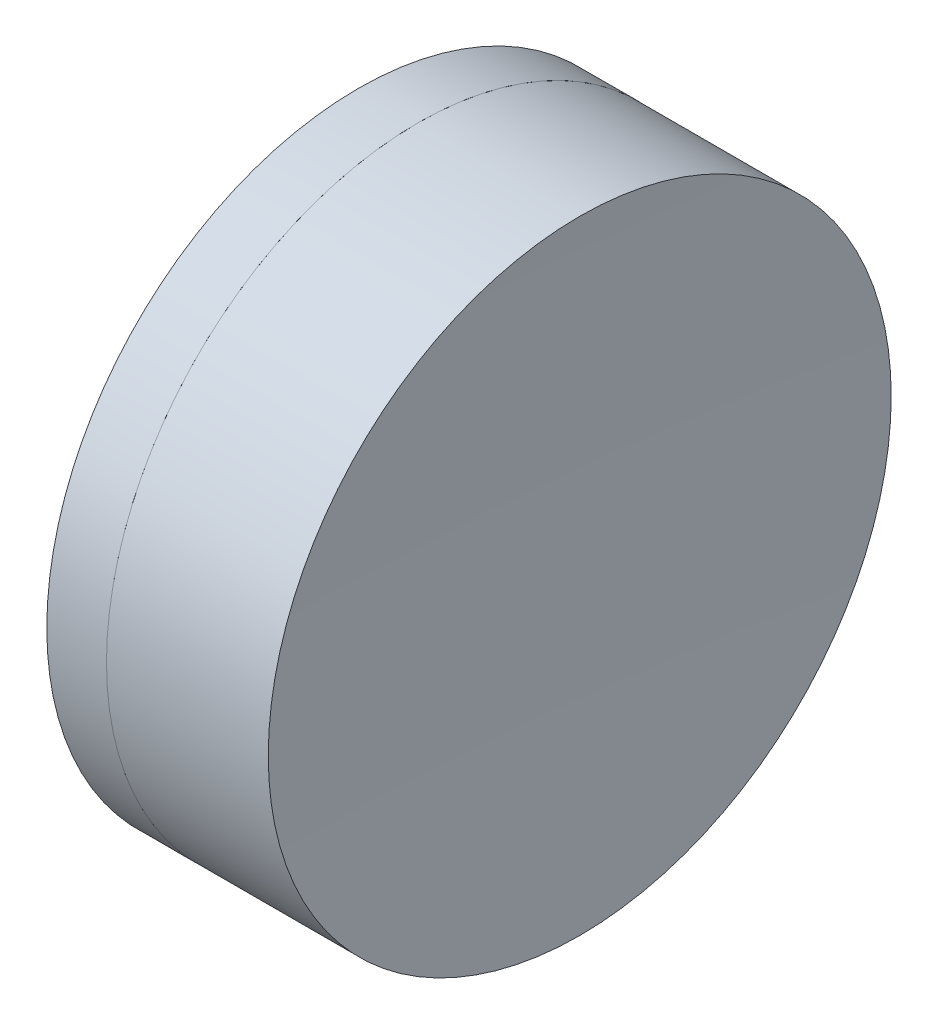
from build123d import *


with BuildPart() as part:
    # 草图1 one side → 旋转1 (revolve)
    with BuildSketch(Plane(origin=(0, 0, 0), x_dir=(1, 0, 0), z_dir=(0, 1, 0)), mode=Mode.PRIVATE) as revolve_1_sk:
        with BuildLine():
            ThreePointArc((22.343710293, 6.35), (20.989318689, 3.302530951), (20.525925179, 0))
            Line((20.525925179, 0), (25.225925179, 0))
            ThreePointArc((25.225925179, 0), (24.802703986, 3.282354081), (23.560724512, 6.35))
            Line((23.560724512, 6.35), (22.343710293, 6.35))
        make_face()
    revolve(revolve_1_sk.sketch.rotate(Axis((-0.816062176, 0, 0), (1, 0, 0)), 180), axis=Axis((-0.816062176, 0, 0), (1, 0, 0)))  # turned: the seam where the file's is


with BuildPart() as body_2:
    # 草图2 one side → 旋转2 (revolve)
    with BuildSketch(Plane(origin=(0, 0, 0), x_dir=(1, 0, 0), z_dir=(0, 1, 0))):
        with BuildLine():
            Line((26.858876785, 6.35), (23.560724512, 6.35))
            ThreePointArc((23.560724512, 6.35), (24.802703986, 3.282354081), (25.225925179, 0))
            Line((25.225925179, 0), (26.725925179, 0))
            ThreePointArc((26.725925179, 0), (26.759166723, 3.175695834), (26.858876785, 6.35))
        make_face()
    revolve(axis=Axis((-0.551919993, 0, 0), (1, 0, 0)))


solid = Compound([part.part, body_2.part])
